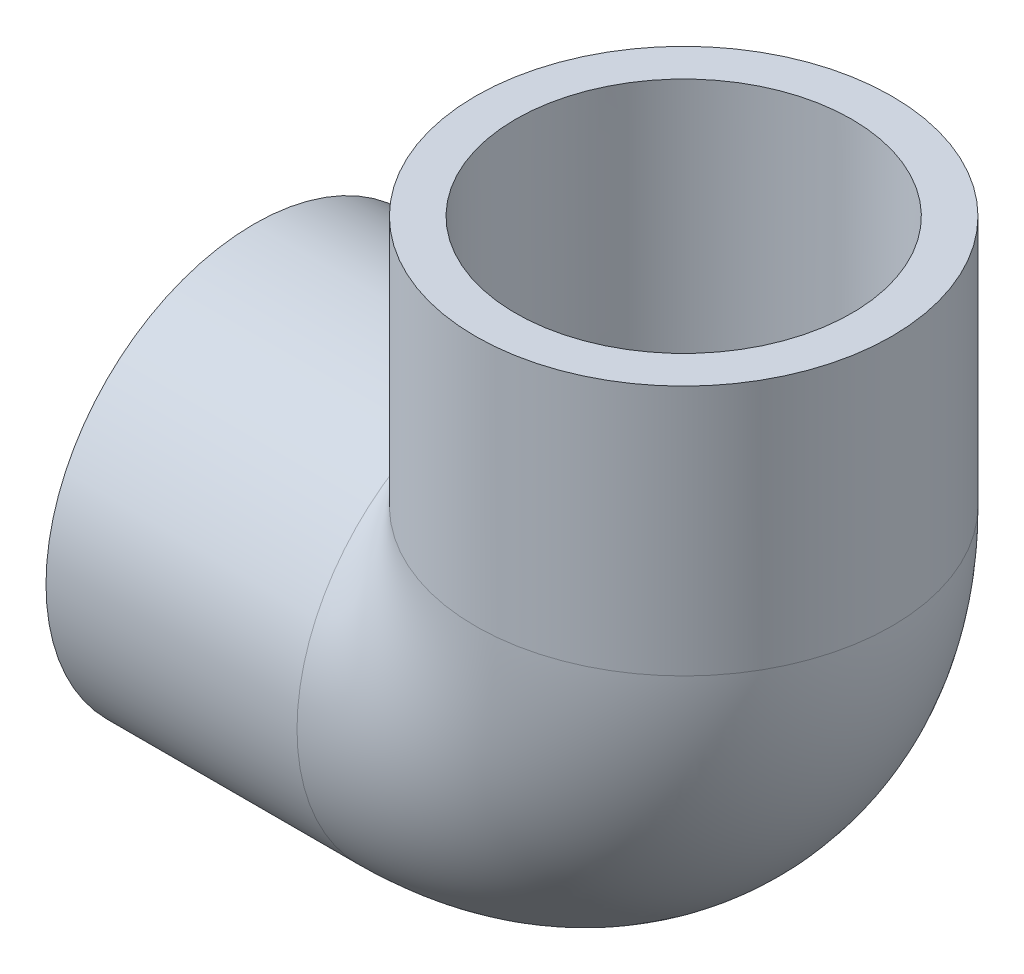
from build123d import *

# Parameters (mm, degrees)
SKETCH3_R   = 16.637
SKETCH3_R_2 = 10.4648


with BuildPart() as part:
    # Sketch1 → Revolve1 (revolve)
    with BuildSketch(Plane.XY):
        Polygon((-34.3408, -16.637), (-14.2748, -16.637), (-14.2748, -13.2842), (-34.3408, -13.4366), align=None)
    revolve(axis=Axis((-34.3408, 0, 0), (1, 0, 0)))



with BuildPart() as body_2:
    # Sketch2 → Revolve2 (revolve)
    with BuildSketch(Plane.XY):
        Polygon((13.4366, 34.3408), (13.2842, 14.2748), (16.637, 14.2748), (16.637, 34.3408), align=None)
    revolve(axis=Axis((0, 0, 0), (0, 1, 0)))


with BuildPart() as part_1:
    add(part.part)

    add(body_2.part)  # Sweep1 merges body 2
    # Sweep1: sweep along a path in Sketch4
    with BuildLine(Plane.XY) as sweep1_path:
        ThreePointArc((-14.2748, 0), (-4.180992, 4.180992), (0, 14.2748))
    # Sketch3 → Sweep1 (sweep)
    with BuildSketch(Plane(origin=(-14.2748, 0, 0), x_dir=(0, 0, -1), z_dir=(1, 0, 0))):
        Circle(SKETCH3_R)
        Circle(SKETCH3_R_2, mode=Mode.SUBTRACT)
    sweep(path=sweep1_path.line)


solid = part_1.part
